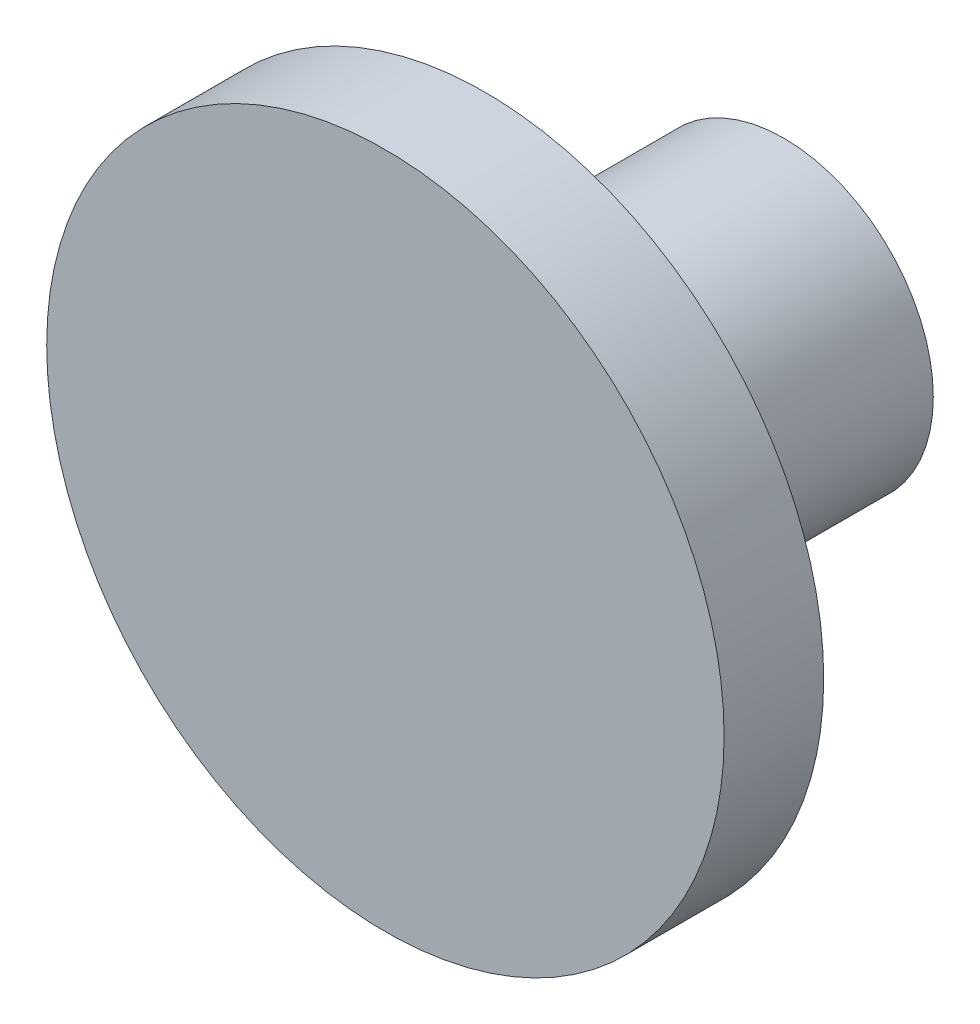
from build123d import *

# Parameters (mm, degrees)
ESBO_O1_R                = 1.5
RESSALTO_EXTRUS_O1_DEPTH = 4
ESBO_O2_R                = 3.4
RESSALTO_EXTRUS_O2_DEPTH = 1


with BuildPart() as part:
    # Esboço1 → Ressalto-extrusão1 (new body)
    with BuildSketch(Plane.XY):
        with Locations((0, 5)):
            Circle(ESBO_O1_R)
    extrude(amount=RESSALTO_EXTRUS_O1_DEPTH)

    # Esboço2 → Ressalto-extrusão2 (add)
    with BuildSketch(Plane(origin=(0, 0, 4), x_dir=(-1, 0, 0), z_dir=(0, 0, -1))):
        with Locations((0, 5)):
            Circle(ESBO_O2_R)
    extrude(amount=RESSALTO_EXTRUS_O2_DEPTH)


solid = part.part
